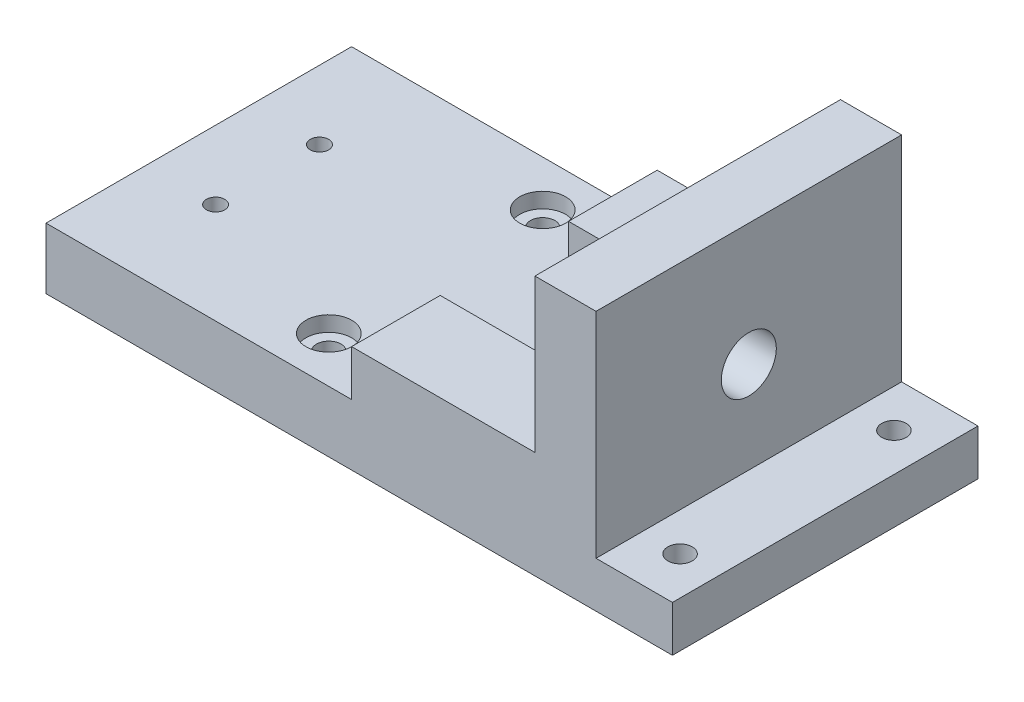
from build123d import *

# Parameters (mm, degrees)
BOSS_EXTRUDE1_DEPTH = 100
SKETCH2_W           = 60
SKETCH2_H           = 42
CUT_EXTRUDE1_DEPTH  = 15
SKETCH3_R           = 3
SKETCH3_R_2         = 4
CUT_EXTRUDE2_DEPTH  = 36
SKETCH5_R           = 9
CUT_EXTRUDE3_DEPTH  = 26
SKETCH6_R           = 4
CUT_EXTRUDE4_DEPTH  = 26
SKETCH6_3_R         = 7.5
CUT_EXTRUDE5_DEPTH  = 5


with BuildPart() as part:
    # Sketch1 → Boss-Extrude1 (new body)
    with BuildSketch(Plane.XY):
        Polygon((-307.269612093, -26.355738605), (-102.269612093, -26.355738605), (-102.269612093, -11.355738605), (-127.269612093, -11.355738605), (-127.269612093, 58.644261395), (-147.269612093, 58.644261395), (-147.269612093, 8.644261395), (-207.269612093, 8.644261395), (-207.269612093, -6.355738605), (-307.269612093, -6.355738605), align=None)
    extrude(amount=BOSS_EXTRUDE1_DEPTH)

    # Sketch2 → Cut-Extrude1 (cut)
    with BuildSketch(Plane(origin=(0, 8.644261395, 0), x_dir=(1, 0, 0), z_dir=(0, 1, 0))):
        with Locations((-177.269612093, -50)):
            Rectangle(SKETCH2_W, SKETCH2_H)
    extrude(amount=-CUT_EXTRUDE1_DEPTH, mode=Mode.SUBTRACT)

    # Sketch3 → Cut-Extrude2 (cut)
    with BuildSketch(Plane(origin=(0, -6.355738605, 0), x_dir=(1, 0, 0), z_dir=(0, 1, 0))):
        with Locations((-284.769612093, -33)):
            Circle(SKETCH3_R)
        with Locations((-114.769612093, -15)):
            Circle(SKETCH3_R_2)
    cut_extrude2 = extrude(amount=-CUT_EXTRUDE2_DEPTH, mode=Mode.SUBTRACT)

    # Mirror1: Cut-Extrude2 across plane
    add(cut_extrude2.mirror(Plane.XY.offset(50)), mode=Mode.SUBTRACT)

    # Sketch5 → Cut-Extrude3 (cut)
    with BuildSketch(Plane(origin=(-127.269612093, 0, 0), x_dir=(0, 0, -1), z_dir=(1, 0, 0))):
        with Locations((-50, 18.644261395)):
            Circle(SKETCH5_R)
    extrude(amount=-CUT_EXTRUDE3_DEPTH, mode=Mode.SUBTRACT)

    # Sketch6 → Cut-Extrude4 (cut)
    with BuildSketch(Plane(origin=(0, -6.355738605, 0), x_dir=(1, 0, 0), z_dir=(0, 1, 0))):
        with Locations((-229.725095616, -15)):
            Circle(SKETCH6_R)
    cut_extrude4 = extrude(amount=-CUT_EXTRUDE4_DEPTH, mode=Mode.SUBTRACT)

    # Sketch6_3 → Cut-Extrude5 (cut)
    with BuildSketch(Plane(origin=(0, -6.355738605, 0), x_dir=(1, 0, 0), z_dir=(0, 1, 0))):
        with Locations((-229.725095616, -15)):
            Circle(SKETCH6_3_R)
    cut_extrude5 = extrude(amount=-CUT_EXTRUDE5_DEPTH, mode=Mode.SUBTRACT)

    # Mirror2: Cut-Extrude4, Cut-Extrude5 across plane
    add(cut_extrude4.mirror(Plane.XY.offset(50)), mode=Mode.SUBTRACT)
    add(cut_extrude5.mirror(Plane.XY.offset(50)), mode=Mode.SUBTRACT)


solid = part.part
